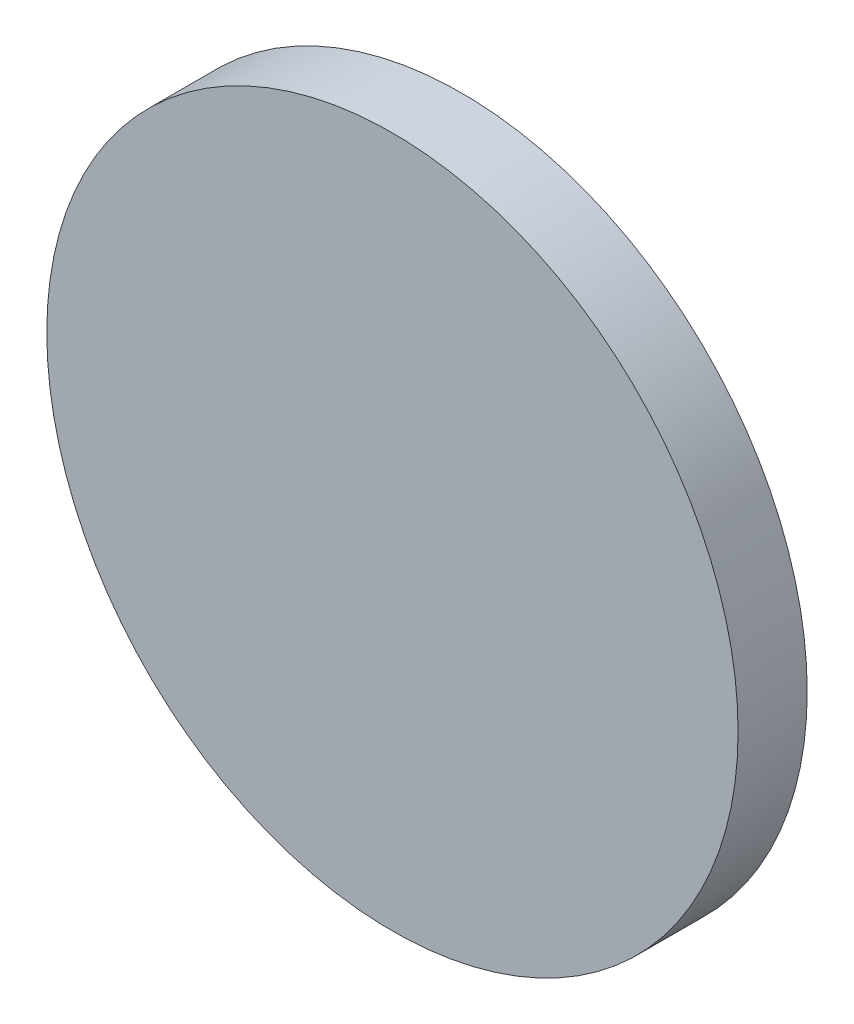
from build123d import *

# Parameters (mm, degrees)
SKETCH1_R           = 15
BOSS_EXTRUDE1_DEPTH = 3


with BuildPart() as part:
    # Sketch1 → Boss-Extrude1 (new body)
    with BuildSketch(Plane.XY):
        with Locations((-85, 68)):
            Circle(SKETCH1_R)
    extrude(amount=BOSS_EXTRUDE1_DEPTH)


solid = part.part
